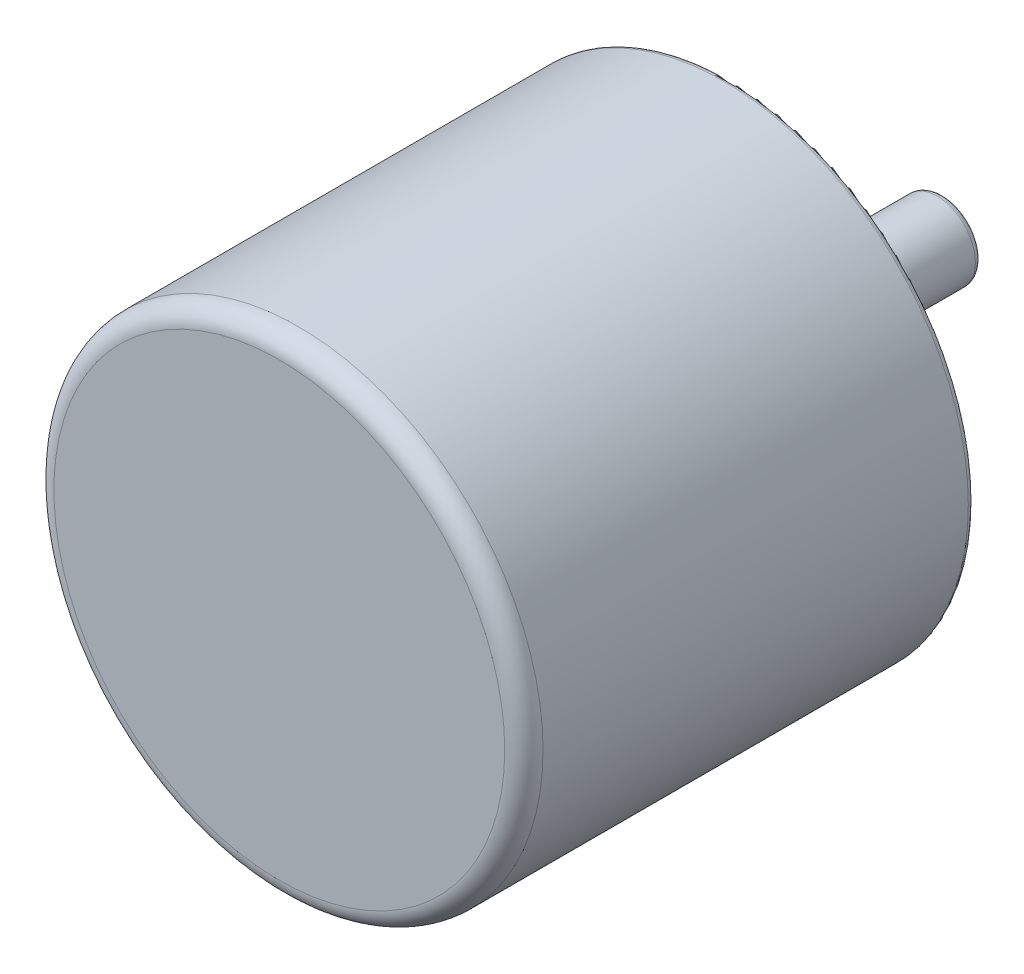
from build123d import *

# Parameters (mm, degrees)
SKETCH1_R           = 19.15
BOSS_EXTRUDE1_DEPTH = 35.3
SKETCH2_R           = 10
SKETCH2_R_2         = 7.5
BOSS_EXTRUDE2_DEPTH = 4.7
SKETCH3_R           = 3
BOSS_EXTRUDE3_DEPTH = 16.7
SKETCH4_R           = 1.008522138
SKETCH4_R_2         = 1.026344308
CUT_EXTRUDE1_DEPTH  = 6.8
FILLET1_R           = 1.5
FILLET2_R           = 0.5
FILLET3_R           = 0.5
FILLET4_R           = 0.5


with BuildPart() as part:
    # Sketch1 → Boss-Extrude1 (new body)
    with BuildSketch(Plane.XY):
        Circle(SKETCH1_R)
    extrude(amount=BOSS_EXTRUDE1_DEPTH)

    # Sketch2 → Boss-Extrude2 (add)
    with BuildSketch(Plane(origin=(0, 0, 0), x_dir=(-1, 0, 0), z_dir=(0, 0, -1))):
        Circle(SKETCH2_R)
        Circle(SKETCH2_R_2, mode=Mode.SUBTRACT)
    extrude(amount=BOSS_EXTRUDE2_DEPTH)

    # Sketch3 → Boss-Extrude3 (add)
    with BuildSketch(Plane(origin=(0, 0, 0), x_dir=(-1, 0, 0), z_dir=(0, 0, -1))):
        Circle(SKETCH3_R)
    extrude(amount=BOSS_EXTRUDE3_DEPTH)

    # Sketch4 → Cut-Extrude1 (cut)
    with BuildSketch(Plane(origin=(0, 0, 0), x_dir=(-1, 0, 0), z_dir=(0, 0, -1))):
        with Locations((-3.959842876, 13.584628975)):
            Circle(SKETCH4_R)
        with Locations((0, 14.15)):
            Circle(SKETCH4_R_2)
        with Locations((12.254259464, -7.075)):
            Circle(SKETCH4_R_2)
        with Locations((13.744555232, -3.362989962)):
            Circle(SKETCH4_R)
        with Locations((-12.254259464, -7.075)):
            Circle(SKETCH4_R_2)
        with Locations((-9.784712355, -10.221639013)):
            Circle(SKETCH4_R)
    extrude(amount=-CUT_EXTRUDE1_DEPTH, mode=Mode.SUBTRACT)

    # Fillet1
    fillet1_edges = [part.edges().sort_by_distance(p)[0] for p in [
        (-19.15, 0, 35.3),
    ]]
    fillet(fillet1_edges, radius=FILLET1_R)

    # Fillet2
    fillet2_edges = [part.edges().sort_by_distance(p)[0] for p in [
        (3, 0, -16.7),
    ]]
    fillet(fillet2_edges, radius=FILLET2_R)

    # Fillet3
    fillet3_edges = [part.edges().sort_by_distance(p)[0] for p in [
        (10, 0, -4.7),
    ]]
    fillet(fillet3_edges, radius=FILLET3_R)

    # Fillet4
    fillet4_edges = [part.edges().sort_by_distance(p)[0] for p in [
        (-19.15, 0, 0),
    ]]
    fillet(fillet4_edges, radius=FILLET4_R)


solid = part.part
